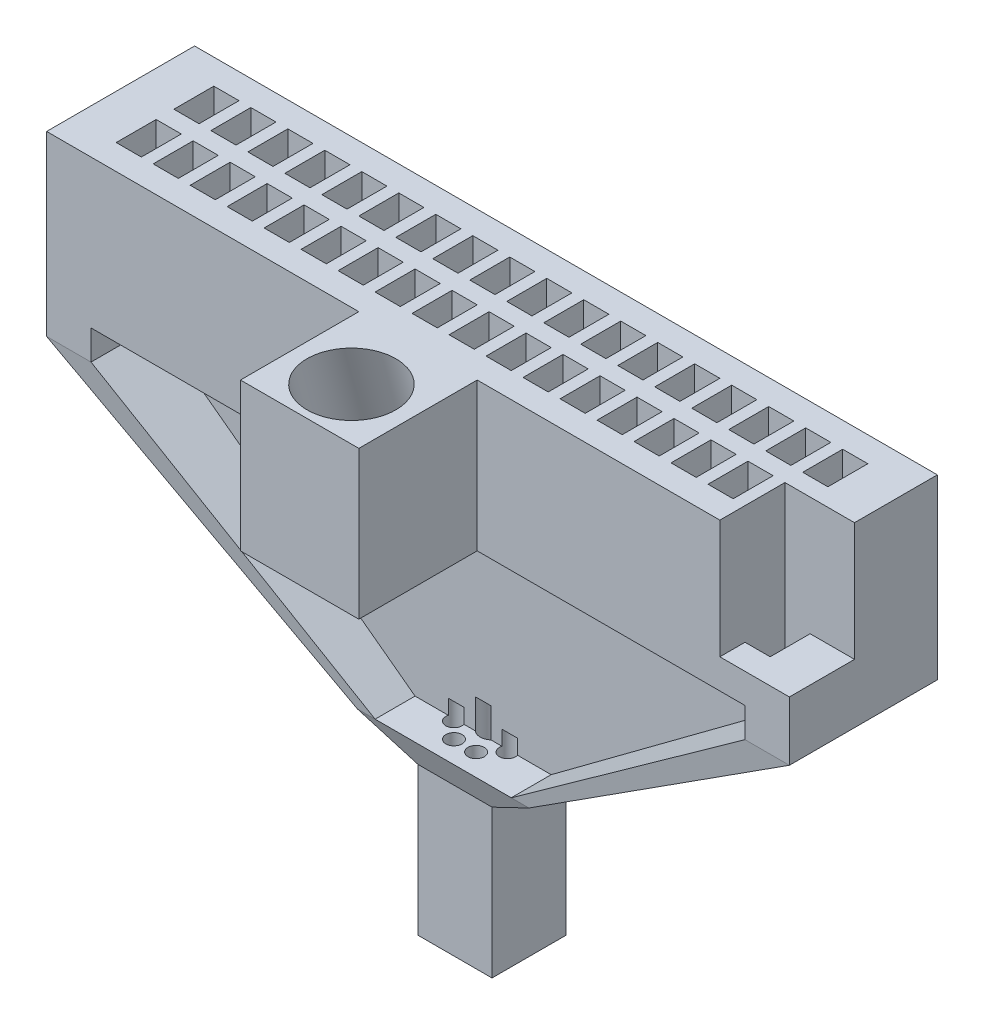
from build123d import *

# Parameters (mm, degrees)
MAIN_BLOCK_W             = 12.7508
MAIN_BLOCK_H             = 2.54
WELL_BLOCK_DEPTH         = 2.54
TOP_HOLES_W              = 0.4318
TOP_HOLES_H              = 0.6858
OMNETICS_WELLS_DEPTH     = 2.54
SKETCH8_W                = 0.762
SKETCH8_H                = 2.54
SUPPORTBEAM1_DEPTH       = 0.508
SKETCH10_W               = 0.762
SKETCH10_H               = 2.54
SUPPORTBEAM2_DEPTH       = 0.508
SKETCH7_W                = 0.3048
SKETCH7_H                = 1.77800034
SKETCH5_W                = 11.226700613
SKETCH5_H                = 0.3048
WALL_DIVIDER_DEPTH       = 0.508
SKETCH6_W                = 2.336782461
SKETCH6_H                = 0.3048
SKETCH12_W               = 2.9464
SKETCH12_H               = 1.77800034
SKETCH13_W               = 1.27
SKETCH13_H               = 1.27
SKETCH13_3_W             = 1.27
SKETCH13_3_H             = 1.27
TETRODE_FUNNEL_DEPTH     = 2.54
SKETCH17_W               = 1.1938
SKETCH17_H               = 1.1176
GROUND_WIRE_HOLE_DEPTH   = 2.032
SKETCH18_R               = 0.1397
TETRODES_DEPTH           = 3.302
SKETCH19_R               = 0.2032
FIBER_OPTIC_HOLE_DEPTH   = 3.556
SKETCH20_W               = 2.032
SKETCH20_H               = 2.54
FIBER_OPTIC_HOLDER_DEPTH = 2.032
SKETCH24_R               = 0.762
SKETCH25_R               = 0.762


with BuildPart() as part:
    # main_block → well_block (new body)
    with BuildSketch(Plane(origin=(0, 0, 0), x_dir=(1, 0, 0), z_dir=(0, 1, 0))):
        with Locations((0.756592766, -0.05080017)):
            Rectangle(MAIN_BLOCK_W, MAIN_BLOCK_H)
    extrude(amount=-WELL_BLOCK_DEPTH)

    # top_holes → omnetics_wells (cut)
    with BuildSketch(Plane(origin=(0, 0, 0), x_dir=(1, 0, 0), z_dir=(0, 1, 0))):
        with Locations((6.154092766, 0.44449983)):
            Rectangle(TOP_HOLES_W, TOP_HOLES_H)
        with Locations((5.519098613, 0.44449983)):
            Rectangle(TOP_HOLES_W, TOP_HOLES_H)
        with Locations((4.884104459, 0.44449983)):
            Rectangle(TOP_HOLES_W, TOP_HOLES_H)
        with Locations((4.249110305, 0.44449983)):
            Rectangle(TOP_HOLES_W, TOP_HOLES_H)
        with Locations((3.614116151, 0.44449983)):
            Rectangle(TOP_HOLES_W, TOP_HOLES_H)
        with Locations((2.979121998, 0.44449983)):
            Rectangle(TOP_HOLES_W, TOP_HOLES_H)
        with Locations((2.344127844, 0.44449983)):
            Rectangle(TOP_HOLES_W, TOP_HOLES_H)
        with Locations((1.70913369, 0.44449983)):
            Rectangle(TOP_HOLES_W, TOP_HOLES_H)
        with Locations((1.074139537, 0.44449983)):
            Rectangle(TOP_HOLES_W, TOP_HOLES_H)
        with Locations((0.439145383, 0.44449983)):
            Rectangle(TOP_HOLES_W, TOP_HOLES_H)
        with Locations((-0.195848771, 0.44449983)):
            Rectangle(TOP_HOLES_W, TOP_HOLES_H)
        with Locations((-0.830842925, 0.44449983)):
            Rectangle(TOP_HOLES_W, TOP_HOLES_H)
        with Locations((-1.465837078, 0.44449983)):
            Rectangle(TOP_HOLES_W, TOP_HOLES_H)
        with Locations((-2.100831232, 0.44449983)):
            Rectangle(TOP_HOLES_W, TOP_HOLES_H)
        with Locations((-2.735825386, 0.44449983)):
            Rectangle(TOP_HOLES_W, TOP_HOLES_H)
        with Locations((-3.370819539, 0.44449983)):
            Rectangle(TOP_HOLES_W, TOP_HOLES_H)
        with Locations((-4.005813693, 0.44449983)):
            Rectangle(TOP_HOLES_W, TOP_HOLES_H)
        with Locations((-4.640807847, 0.44449983)):
            Rectangle(TOP_HOLES_W, TOP_HOLES_H)
        with Locations((5.519098613, -0.54610017)):
            Rectangle(TOP_HOLES_W, TOP_HOLES_H)
        with Locations((4.884104459, -0.54610017)):
            Rectangle(TOP_HOLES_W, TOP_HOLES_H)
        with Locations((4.249110305, -0.54610017)):
            Rectangle(TOP_HOLES_W, TOP_HOLES_H)
        with Locations((3.614116151, -0.54610017)):
            Rectangle(TOP_HOLES_W, TOP_HOLES_H)
        with Locations((2.979121998, -0.54610017)):
            Rectangle(TOP_HOLES_W, TOP_HOLES_H)
        with Locations((2.344127844, -0.54610017)):
            Rectangle(TOP_HOLES_W, TOP_HOLES_H)
        with Locations((1.70913369, -0.54610017)):
            Rectangle(TOP_HOLES_W, TOP_HOLES_H)
        with Locations((1.074139537, -0.54610017)):
            Rectangle(TOP_HOLES_W, TOP_HOLES_H)
        with Locations((0.439145383, -0.54610017)):
            Rectangle(TOP_HOLES_W, TOP_HOLES_H)
        with Locations((-0.195848771, -0.54610017)):
            Rectangle(TOP_HOLES_W, TOP_HOLES_H)
        with Locations((-0.830842925, -0.54610017)):
            Rectangle(TOP_HOLES_W, TOP_HOLES_H)
        with Locations((-1.465837078, -0.54610017)):
            Rectangle(TOP_HOLES_W, TOP_HOLES_H)
        with Locations((-2.100831232, -0.54610017)):
            Rectangle(TOP_HOLES_W, TOP_HOLES_H)
        with Locations((-2.735825386, -0.54610017)):
            Rectangle(TOP_HOLES_W, TOP_HOLES_H)
        with Locations((-3.370819539, -0.54610017)):
            Rectangle(TOP_HOLES_W, TOP_HOLES_H)
        with Locations((-4.005813693, -0.54610017)):
            Rectangle(TOP_HOLES_W, TOP_HOLES_H)
        with Locations((-4.640807847, -0.54610017)):
            Rectangle(TOP_HOLES_W, TOP_HOLES_H)
        with Locations((6.154092766, -0.54610017)):
            Rectangle(TOP_HOLES_W, TOP_HOLES_H)
    extrude(amount=-OMNETICS_WELLS_DEPTH, mode=Mode.SUBTRACT)

    # Sketch8 → supportbeam1 (add)
    with BuildSketch(Plane.XZ.offset(2.54)):
        with Locations((-5.237707847, 0.05080017)):
            Rectangle(SKETCH8_W, SKETCH8_H)
    extrude(amount=SUPPORTBEAM1_DEPTH)

    # Sketch10 → supportbeam2 (add)
    with BuildSketch(Plane.XZ.offset(2.54)):
        with Locations((6.750992766, 0.05080017)):
            Rectangle(SKETCH10_W, SKETCH10_H)
    extrude(amount=SUPPORTBEAM2_DEPTH)

    # Sketch9 → section 0 of arm1
    with BuildSketch(Plane(origin=(0, -6.35, 0), x_dir=(1, 0, 0), z_dir=(0, 1, 0)), mode=Mode.PRIVATE) as arm1_s0:
        Polygon((1.92503369, -0.88900017), (1.924934303, 0.88900017), (2.229734303, 0.889017208), (2.22983369, -0.888983133), align=None)
    # loft up to a face of the part (arm1)
    loft([arm1_s0.sketch, part.faces().sort_by_distance((6.750992766, -3.048, 0.05080017))[0]])

    # Sketch7 → section 0 of arm2
    with BuildSketch(Plane(origin=(0, -6.35, 0), x_dir=(1, 0, 0), z_dir=(0, 1, 0)), mode=Mode.PRIVATE) as arm2_s0:
        with Locations((-0.564148771, 0)):
            Rectangle(SKETCH7_W, SKETCH7_H)
    # loft up to a face of the part (arm2)
    loft([arm2_s0.sketch, part.faces().sort_by_distance((-5.237707847, -3.048, 0.05080017))[0]])

    # Sketch5 → wall_divider (add)
    with BuildSketch(Plane.XZ.offset(2.54)):
        with Locations((0.75664246, 0.05080017)):
            Rectangle(SKETCH5_W, SKETCH5_H)
    extrude(amount=WALL_DIVIDER_DEPTH)

    # Sketch6 → section 1 of wall_divider2
    with BuildSketch(Plane(origin=(0, -6.35, 0), x_dir=(1, 0, 0), z_dir=(0, 1, 0)), mode=Mode.PRIVATE) as wall_divider2_s1:
        with Locations((0.756642459, -0.05080017)):
            Rectangle(SKETCH6_W, SKETCH6_H)
    # loft from a face of the part (wall_divider2)
    loft([part.faces().sort_by_distance((0.75664246, -3.048, 0.05080017))[0], wall_divider2_s1.sketch])

    # Sketch12 → exit_base section 0
    with BuildSketch(Plane(origin=(0, -6.35, 0), x_dir=(1, 0, 0), z_dir=(0, 1, 0))):
        with Locations((0.756651229, 0)):
            Rectangle(SKETCH12_W, SKETCH12_H)
    # Sketch13 → exit_base section 1
    with BuildSketch(Plane(origin=(0, -6.858, 0), x_dir=(1, 0, 0), z_dir=(0, 1, 0))):
        with Locations((0.756639537, -0.050800172)):
            Rectangle(SKETCH13_W, SKETCH13_H)
    loft()

    # Sketch13_3 → tetrode_funnel (add)
    with BuildSketch(Plane(origin=(0, -6.858, 0), x_dir=(1, 0, 0), z_dir=(0, 1, 0))):
        with Locations((0.756639537, -0.050800172)):
            Rectangle(SKETCH13_3_W, SKETCH13_3_H)
    extrude(amount=-TETRODE_FUNNEL_DEPTH)

    # Sketch17 → ground_wire_hole (cut)
    with BuildSketch(Plane(origin=(0, 0, 0), x_dir=(1, 0, 0), z_dir=(0, 1, 0))):
        with Locations((6.535092766, -0.76200017)):
            Rectangle(SKETCH17_W, SKETCH17_H)
    extrude(amount=-GROUND_WIRE_HOLE_DEPTH, mode=Mode.SUBTRACT)

    # Sketch18 → tetrodes (cut)
    with BuildSketch(Plane(origin=(0, -9.398, 0), x_dir=(-1, 0, 0), z_dir=(0, -1, 0))):
        with Locations((-1.213839537, -0.241300172)):
            Circle(SKETCH18_R)
        with Locations((-1.213839537, 0.139699828)):
            Circle(SKETCH18_R)
        with Locations((-0.944431853, 0.409107512)):
            Circle(SKETCH18_R)
        with Locations((-0.563431853, 0.409107512)):
            Circle(SKETCH18_R)
        with Locations((-0.294024169, 0.139699828)):
            Circle(SKETCH18_R)
        with Locations((-0.294024169, -0.241300172)):
            Circle(SKETCH18_R)
        with Locations((-0.563431853, -0.510707855)):
            Circle(SKETCH18_R)
        with Locations((-0.944431853, -0.510707855)):
            Circle(SKETCH18_R)
    extrude(amount=-TETRODES_DEPTH, mode=Mode.SUBTRACT)

    # Sketch19 → fiber_optic_hole (cut)
    with BuildSketch(Plane.XZ.offset(9.398)):
        with Locations((0.756639537, 0.050800172)):
            Circle(SKETCH19_R)
    extrude(amount=-FIBER_OPTIC_HOLE_DEPTH, mode=Mode.SUBTRACT)

    # Sketch20 → fiber_optic_holder (add)
    with BuildSketch(Plane.XY.offset(1.32080017)):
        with Locations((0.756592766, -1.27)):
            Rectangle(SKETCH20_W, SKETCH20_H)
    extrude(amount=FIBER_OPTIC_HOLDER_DEPTH)

    # Sketch24 → Cut-Loft1 section 0
    with BuildSketch(Plane.XZ.offset(2.54)):
        with Locations((0.760600593, 1.77800017)):
            Circle(SKETCH24_R)
    # Sketch25 → Cut-Loft1 section 1
    with BuildSketch(Plane(origin=(0, 0, 0), x_dir=(1, 0, 0), z_dir=(0, 1, 0))):
        with Locations((0.756592766, -2.46380017)):
            Circle(SKETCH25_R)
    loft(mode=Mode.SUBTRACT)


solid = part.part
